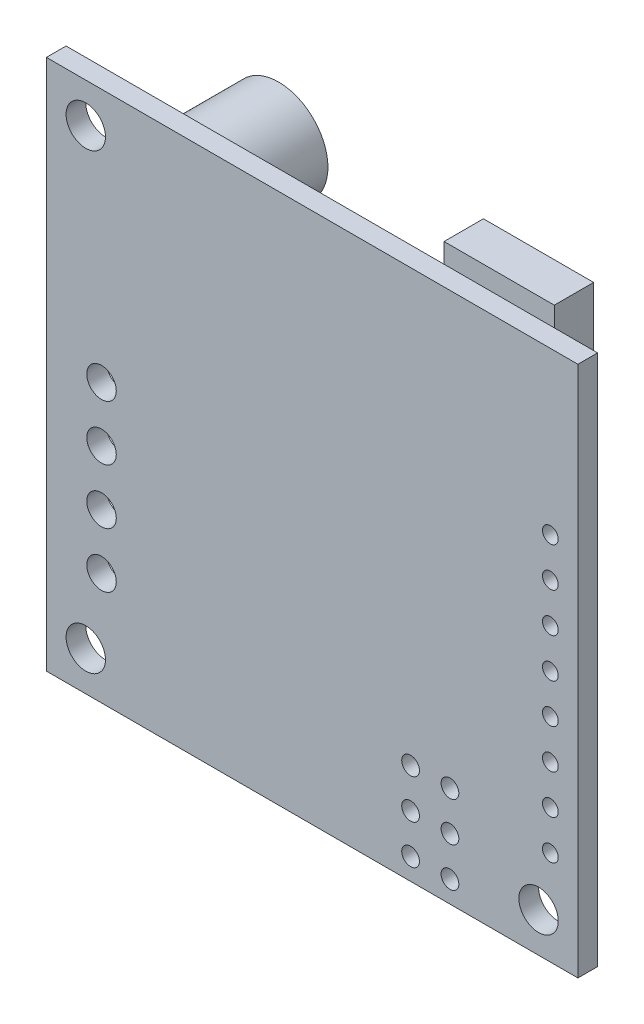
from build123d import *

# Parameters (mm, degrees)
SKETCH1_W       = 34.29
SKETCH1_H       = 34.29
EXTRUDE1_DEPTH  = 1.27
SKETCH2_R       = 1.27
EXTRUDE2_DEPTH  = 2.27
SKETCH3_R       = 0.9525
EXTRUDE3_DEPTH  = 2.27
SKETCH4_R       = 0.5715
EXTRUDE4_DEPTH  = 2.27
LPATTERN1_COUNT = 3
LPATTERN1_PITCH = 2.54
SKETCH5_R       = 0.508
EXTRUDE5_DEPTH  = 2.27
LPATTERN2_COUNT = 8
LPATTERN2_PITCH = 2.54
SKETCH7_W       = 7.030885781
SKETCH7_H       = 5.062237762
SKETCH7_W_2     = 7.874
SKETCH7_H_2     = 7.62
SKETCH7_W_3     = 3.281080031
SKETCH7_H_3     = 6.374669774
SKETCH7_W_4     = 3.421697746
SKETCH7_H_4     = 4.921620047
SKETCH7_W_5     = 2.577991453
SKETCH7_H_5     = 1.453049728
SKETCH7_W_6     = 3.140462315
SKETCH7_H_6     = 1.406177157
SKETCH7_W_7     = 3.327952603
SKETCH7_H_7     = 1.078069153
EXTRUDE7_DEPTH  = 1.27
SKETCH8_R       = 3.175
EXTRUDE8_DEPTH  = 5.08
SKETCH9_W       = 7.112
SKETCH9_H       = 8.89
EXTRUDE9_DEPTH  = 2.54


with BuildPart() as part:
    # Sketch1 → Extrude1 (new body)
    with BuildSketch(Plane.XY):
        Rectangle(SKETCH1_W, SKETCH1_H)
    extrude(amount=EXTRUDE1_DEPTH)

    # Sketch2 → Extrude2 (cut, through all)
    with BuildSketch(Plane.XY.offset(1.27)):
        with Locations((-14.605, 14.605)):
            Circle(SKETCH2_R)
        with Locations((-14.605, -14.605)):
            Circle(SKETCH2_R)
        with Locations((14.605, -14.605)):
            Circle(SKETCH2_R)
    extrude(amount=-EXTRUDE2_DEPTH, mode=Mode.SUBTRACT)

    # Sketch3 → Extrude3 (cut, through all)
    with BuildSketch(Plane.XY.offset(1.27)):
        with Locations((-13.589, 0.762)):
            Circle(SKETCH3_R)
        with Locations((-13.589, -2.794)):
            Circle(SKETCH3_R)
        with Locations((-13.589, -6.35)):
            Circle(SKETCH3_R)
        with Locations((-13.589, -9.906)):
            Circle(SKETCH3_R)
    extrude(amount=-EXTRUDE3_DEPTH, mode=Mode.SUBTRACT)

    # Sketch4 → Extrude4 (cut, through all)
    with BuildSketch(Plane.XY.offset(1.27)):
        with Locations((6.35, -15.748)):
            Circle(SKETCH4_R)
        with Locations((8.89, -15.748)):
            Circle(SKETCH4_R)
    extrude4 = extrude(amount=-EXTRUDE4_DEPTH, mode=Mode.SUBTRACT)

    # LPattern1: Extrude4 ×3
    with Locations(*[(0, i * LPATTERN1_PITCH, 0) for i in range(1, LPATTERN1_COUNT)]):
        add(extrude4, mode=Mode.SUBTRACT)

    # Sketch5 → Extrude5 (cut, through all)
    with BuildSketch(Plane.XY.offset(1.27)):
        with Locations((15.367, -11.049)):
            Circle(SKETCH5_R)
    extrude5 = extrude(amount=-EXTRUDE5_DEPTH, mode=Mode.SUBTRACT)

    # LPattern2: Extrude5 ×8
    with Locations(*[(0, i * LPATTERN2_PITCH, 0) for i in range(1, LPATTERN2_COUNT)]):
        add(extrude5, mode=Mode.SUBTRACT)

    # Sketch7 → Extrude7 (add)
    with BuildSketch(Plane(origin=(0, 0, 0), x_dir=(-1, 0, 0), z_dir=(0, 0, -1))):
        with Locations((-8.390190366, 1.781157731)):
            Rectangle(SKETCH7_W, SKETCH7_H)
        with Locations((5.334, -9.525)):
            Rectangle(SKETCH7_W_2, SKETCH7_H_2)
        with Locations((1.640540016, 6.655905206)):
            Rectangle(SKETCH7_W_3, SKETCH7_H_3)
        with Locations((6.585596348, -0.210926574)):
            Rectangle(SKETCH7_W_4, SKETCH7_H_4)
        with Locations((-3.585751749, 11.64783411)):
            Rectangle(SKETCH7_W_5, SKETCH7_H_5)
        with Locations((1.992084305, 11.24941725)):
            Rectangle(SKETCH7_W_6, SKETCH7_H_6)
        with Locations((-10.241656955, -5.36690948)):
            Rectangle(SKETCH7_W_7, SKETCH7_H_7)
    extrude(amount=EXTRUDE7_DEPTH)

    # Sketch8 → Extrude8 (add)
    with BuildSketch(Plane(origin=(0, 0, 0), x_dir=(-1, 0, 0), z_dir=(0, 0, -1))):
        with Locations((8.509, 13.733663559)):
            Circle(SKETCH8_R)
        with Locations((12.827, 6.731)):
            Circle(SKETCH8_R)
    extrude(amount=EXTRUDE8_DEPTH)

    # Sketch9 → Extrude9 (add)
    with BuildSketch(Plane(origin=(0, 0, 0), x_dir=(-1, 0, 0), z_dir=(0, 0, -1))):
        with Locations((-10.795, 13.97)):
            Rectangle(SKETCH9_W, SKETCH9_H)
    extrude(amount=EXTRUDE9_DEPTH)


solid = part.part
